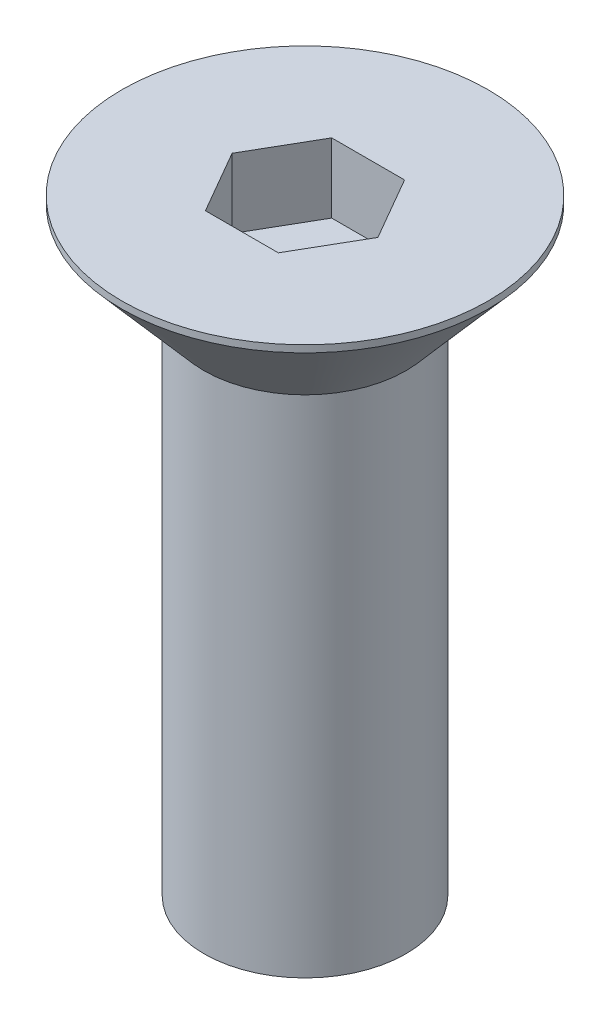
from build123d import *

# Parameters (mm, degrees)
SKETCH2_R          = 6.35
LENGTH_DEPTH       = 31.75
CUT_EXTRUDE1_DEPTH = 4.3688


with BuildPart() as part:
    # Sketch1 → Head (revolve)
    with BuildSketch(Plane.XY):
        Polygon((0, 6.3754), (11.509375, 6.3754), (11.509375, 5.935182001), (6.35, 0), (0, 0), align=None)
    revolve(axis=Axis((0, -1.82358767, 0), (0, 1, 0)))

    # Sketch2 → Length (add)
    with BuildSketch(Plane(origin=(0, 0, 0), x_dir=(1, 0, 0), z_dir=(0, 1, 0))):
        Circle(SKETCH2_R)
    extrude(amount=-LENGTH_DEPTH)

    # Sketch3 → Cut-Extrude1 (cut)
    with BuildSketch(Plane(origin=(0, 6.3754, 0), x_dir=(-1, 0, 0), z_dir=(0, 1, 0))):
        Polygon((2.291358881, 3.96875), (-2.291358881, 3.96875), (-4.582717762, 0), (-2.291358881, -3.96875), (2.291358881, -3.96875), (4.582717762, 0), align=None)
    extrude(amount=-CUT_EXTRUDE1_DEPTH, mode=Mode.SUBTRACT)


solid = part.part
